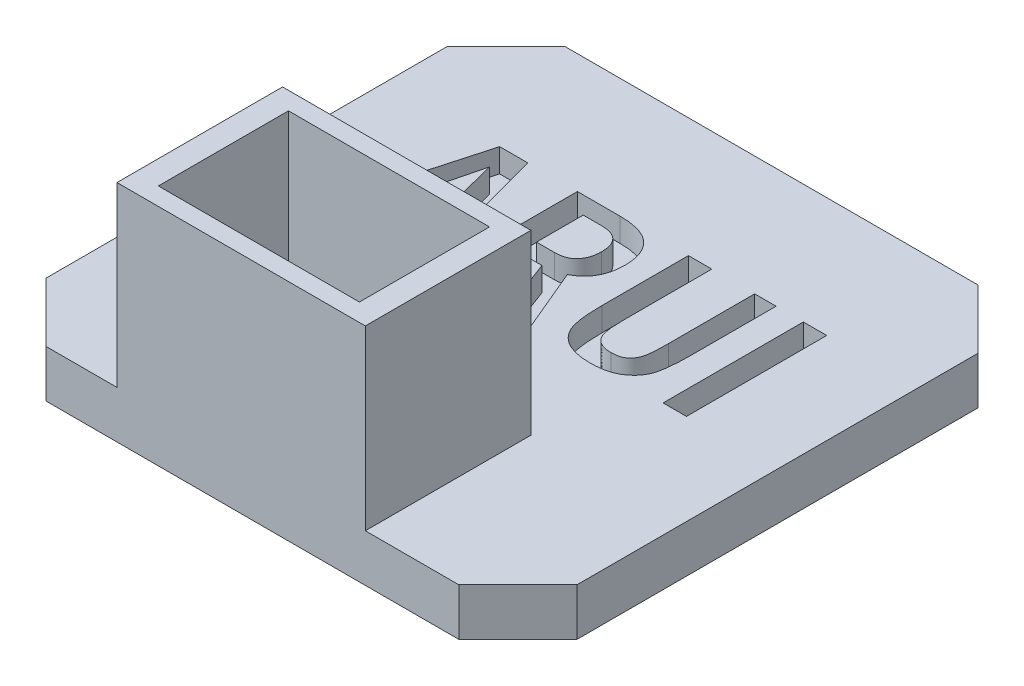
from build123d import *

# Parameters (mm, degrees)
SKETCH_1_W               = 44.9
SKETCH_1_H               = 43.9
SKETCH_1_W_2             = 15
SKETCH_1_H_2             = 8
EXTRUDE_1_DEPTH          = 4
SKETCH_2_W               = 21
SKETCH_2_H               = 14
EXTRUDE_2_DEPTH          = 15
CHAMFER_1_SIZE           = 5
SKETCH_6_W               = 1.976106771
SKETCH_6_H               = 11.856640625
CUT_EXTRUDE_2_DEPTH      = 2
SKETCH_8_W               = 17
SKETCH_8_H               = 11
CUT_EXTRUDE_3_DEPTH      = 16
CUT_EXTRUDE_3_DEPTH_BACK = 5


with BuildPart() as part:
    # 草圖1 → 填料-伸長1 (new body)
    with BuildSketch(Plane(origin=(0, 0, 0), x_dir=(1, 0, 0), z_dir=(0, 1, 0))):
        Rectangle(SKETCH_1_W, SKETCH_1_H)
        with Locations((-0.95, -14.95)):
            Rectangle(SKETCH_1_W_2, SKETCH_1_H_2, mode=Mode.SUBTRACT)
    extrude(amount=EXTRUDE_1_DEPTH)

    # 草圖2 → 填料-伸長2 (add)
    with BuildSketch(Plane(origin=(0, 4, 0), x_dir=(1, 0, 0), z_dir=(0, 1, 0))):
        with Locations((-0.95, -14.95)):
            Rectangle(SKETCH_2_W, SKETCH_2_H)
    extrude(amount=EXTRUDE_2_DEPTH)

    # 導角1
    chamfer_1_edges = [part.edges().sort_by_distance(p)[0] for p in [
        (22.45, 2, 21.95),
        (-22.45, 2, 21.95),
        (-22.45, 2, -21.95),
        (22.45, 2, -21.95),
    ]]
    chamfer(chamfer_1_edges, length=CHAMFER_1_SIZE)

    # 草圖6 → 除料-伸長2 (cut)
    with BuildSketch(Plane(origin=(0, 4, 0), x_dir=(1, 0, 0), z_dir=(0, 1, 0))):
        with Locations((13.763161733, 5.928320313)):
            Rectangle(SKETCH_6_W, SKETCH_6_H)
        with BuildLine():
            Line((3.059250057, 11.856640625), (5.035356828, 11.856640625))
            Line((5.035356828, 11.856640625), (5.035356828, 4.551735518))
            add(Edge.make_bspline(
                [(5.035356828, 4.551735518), (5.036076363, 4.453101504), (5.03746547, 4.262682412), (5.041721712, 3.986432719), (5.052471557, 3.730843331), (5.065419378, 3.494966916), (5.079852308, 3.27948879), (5.100219748, 3.082906695), (5.126020768, 2.907092971), (5.161907363, 2.702518739), (5.227181859, 2.471396441), (5.346042075, 2.220817069), (5.505658083, 2.000940309), (5.703716477, 1.813287236), (5.940999948, 1.661095057), (6.219106546, 1.557611062), (6.532345348, 1.491403159), (6.753787388, 1.485287872), (6.869945535, 1.482080078)],
                knots=[0, 0, 0, 0, 0.000295913, 0.000571278, 0.000828789, 0.00106329, 0.001279978, 0.00147661, 0.001656006, 0.001812962, 0.002099601, 0.002373508, 0.002640623, 0.002909996, 0.003187659, 0.003480095, 0.003795491, 0.004143463, 0.004143463, 0.004143463, 0.004143463], degree=3))
            add(Edge.make_bspline(
                [(6.869945535, 1.482080078), (6.979108166, 1.485323674), (7.185914857, 1.491468608), (7.478103452, 1.542772134), (7.734040216, 1.627547385), (7.95021072, 1.755507522), (8.133767296, 1.912470394), (8.286413423, 2.09937152), (8.408543434, 2.31572029), (8.488752812, 2.518695759), (8.538719302, 2.708124745), (8.572249599, 2.884248328), (8.595337293, 3.09258123), (8.619330721, 3.330911167), (8.636733743, 3.600388759), (8.649285633, 3.901507913), (8.656877974, 4.234353462), (8.65776025, 4.466820697), (8.658219241, 4.587758297)],
                knots=[0, 0, 0, 0, 0.000327274, 0.000620015, 0.000886919, 0.0011314, 0.001368624, 0.001608139, 0.001851331, 0.00211126, 0.002260431, 0.002438567, 0.002648567, 0.002888979, 0.003157183, 0.003458505, 0.003793091, 0.004155901, 0.004155901, 0.004155901, 0.004155901], degree=3))
            Line((8.658219241, 4.587758297), (8.658219241, 11.856640625))
            Line((8.658219241, 11.856640625), (10.469650447, 11.856640625))
            Line((10.469650447, 11.856640625), (10.469650447, 4.662376912))
            add(Edge.make_bspline(
                [(10.469650447, 4.662376912), (10.469685194, 4.522559264), (10.469752785, 4.25057684), (10.455113748, 3.855177984), (10.438192626, 3.484519322), (10.413661802, 3.138502656), (10.376356615, 2.817901568), (10.336730834, 2.521504109), (10.287549939, 2.250256089), (10.231684945, 2.000580883), (10.162505873, 1.767205545), (10.071732473, 1.547542781), (9.960736289, 1.338048469), (9.828661623, 1.139809468), (9.677928336, 0.950611132), (9.509049938, 0.769826189), (9.315912759, 0.603686172), (9.1088874, 0.442574938), (8.880127688, 0.298580443), (8.631190093, 0.175649961), (8.365081478, 0.068421916), (8.078074224, -0.013645552), (7.774795746, -0.085791287), (7.451596287, -0.129284291), (7.110649151, -0.158790725), (6.876876836, -0.162677818), (6.756731085, -0.164675564)],
                knots=[0, 0, 0, 0, 0.000419416, 0.000815875, 0.001186833, 0.001532581, 0.001856224, 0.002154976, 0.002429534, 0.002682951, 0.002922259, 0.003158784, 0.003394749, 0.003632391, 0.003872293, 0.004119842, 0.004373272, 0.004635736, 0.004906299, 0.005182468, 0.005467717, 0.005765681, 0.006077149, 0.006402098, 0.006742919, 0.007103294, 0.007103294, 0.007103294, 0.007103294], degree=3))
            add(Edge.make_bspline(
                [(6.756731085, -0.164675564), (6.572088823, -0.160672713), (6.213313186, -0.152894832), (5.693888541, -0.080141082), (5.212443662, 0.040519199), (4.839217856, 0.180134285), (4.562586357, 0.318206014), (4.372061993, 0.439268416), (4.190774021, 0.571595268), (4.024911338, 0.720227999), (3.870905603, 0.884748387), (3.730939107, 1.063229374), (3.603348846, 1.25712115), (3.484339549, 1.467460569), (3.383176765, 1.710084607), (3.296442596, 1.990166437), (3.223495537, 2.312081765), (3.161765625, 2.675333521), (3.117259984, 3.080076219), (3.084216843, 3.526351598), (3.063829241, 4.01463861), (3.060816635, 4.354447779), (3.059250057, 4.531151072)],
                knots=[0, 0, 0, 0, 0.000553691, 0.00107587, 0.001569501, 0.002040208, 0.002268051, 0.002495792, 0.002716565, 0.002940717, 0.003162806, 0.003391866, 0.003620231, 0.003858652, 0.004115764, 0.0044071, 0.004737274, 0.005105293, 0.005511909, 0.005958303, 0.006447616, 0.006977722, 0.006977722, 0.006977722, 0.006977722], degree=3))
            Line((3.059250057, 4.531151072), (3.059250057, 11.856640625))
        make_face()
        with BuildLine():
            Line((-6.327257105, 11.856640625), (-2.727552193, 11.856640625))
            add(Edge.make_bspline(
                [(-2.727552193, 11.856640625), (-2.569654474, 11.854501299), (-2.264428289, 11.850365847), (-1.82306127, 11.809422514), (-1.414120553, 11.738897543), (-1.03504224, 11.648002947), (-0.6908152, 11.517865904), (-0.373541071, 11.37206399), (-0.091926106, 11.190128252), (0.157855246, 10.98196376), (0.377514959, 10.749773263), (0.567450669, 10.492140853), (0.725912096, 10.210547384), (0.860114733, 9.906330602), (0.95784615, 9.576430181), (1.030283457, 9.223550245), (1.074257755, 8.847267053), (1.080128778, 8.588120925), (1.083143286, 8.455061001)],
                knots=[0, 0, 0, 0, 0.000473617, 0.000915531, 0.001327967, 0.001718004, 0.002082707, 0.002430288, 0.002763606, 0.003085145, 0.003403675, 0.003720171, 0.00404283, 0.004371235, 0.004715535, 0.00507281, 0.005451014, 0.005850136, 0.005850136, 0.005850136, 0.005850136], degree=3))
            add(Edge.make_bspline(
                [(1.083143286, 8.455061001), (1.077874288, 8.278897277), (1.067660165, 7.937398216), (0.98435292, 7.445373037), (0.848181333, 6.992498268), (0.657388108, 6.578527022), (0.407656268, 6.205410431), (0.098975839, 5.877643903), (-0.259123171, 5.583123287), (-0.531825254, 5.42861993), (-0.671680695, 5.349382782)],
                knots=[0, 0, 0, 0, 0.000528235, 0.001024001, 0.001492021, 0.001943276, 0.002386447, 0.002832506, 0.003289816, 0.003771252, 0.003771252, 0.003771252, 0.003771252], degree=3))
            Line((-0.671680695, 5.349382782), (1.577169979, 0))
            Line((1.577169979, 0), (-0.566185412, 0))
            Line((-0.566185412, 0), (-2.408493287, 4.940266927))
            Line((-2.408493287, 4.940266927), (-4.351150334, 4.940266927))
            Line((-4.351150334, 4.940266927), (-4.351150334, 0))
            Line((-4.351150334, 0), (-6.327257105, 0))
            Line((-6.327257105, 0), (-6.327257105, 11.856640625))
        make_face()
        with BuildLine():
            Line((-4.351150334, 10.374560547), (-4.351150334, 6.422347005))
            Line((-4.351150334, 6.422347005), (-2.84848581, 6.422347005))
            add(Edge.make_bspline(
                [(-2.84848581, 6.422347005), (-2.766891206, 6.42318571), (-2.609163984, 6.424806977), (-2.381414683, 6.455471211), (-2.169798722, 6.497108704), (-1.974894326, 6.559618036), (-1.796318315, 6.638643077), (-1.635093402, 6.737925118), (-1.489496191, 6.853531163), (-1.321825512, 7.034798612), (-1.14459384, 7.293601165), (-0.999561359, 7.650998331), (-0.905685397, 8.04799541), (-0.897318819, 8.327547685), (-0.892963485, 8.473072391)],
                knots=[0, 0, 0, 0, 0.000244562, 0.000472753, 0.00068823, 0.000890849, 0.001085485, 0.001272594, 0.001457443, 0.001641286, 0.002011681, 0.002391108, 0.002792447, 0.003228214, 0.003228214, 0.003228214, 0.003228214], degree=3))
            add(Edge.make_bspline(
                [(-0.892963485, 8.473072391), (-0.894279915, 8.549484378), (-0.896845222, 8.698387142), (-0.921435121, 8.913994847), (-0.95504089, 9.116257437), (-1.010421463, 9.302883616), (-1.078825106, 9.474653372), (-1.162439303, 9.631740361), (-1.259889976, 9.774243344), (-1.375072383, 9.901052819), (-1.502951485, 10.015647003), (-1.650085041, 10.110460751), (-1.809818319, 10.193746383), (-1.985420652, 10.259709745), (-2.175655038, 10.312163257), (-2.380987364, 10.346000099), (-2.600878696, 10.370767484), (-2.752348144, 10.373269853), (-2.83047442, 10.374560547)],
                knots=[0, 0, 0, 0, 0.000229132, 0.000446506, 0.000650411, 0.00084339, 0.001029257, 0.001204225, 0.001376235, 0.001545686, 0.00171706, 0.001889762, 0.002069286, 0.002256608, 0.002451363, 0.002660335, 0.002880268, 0.003114543, 0.003114543, 0.003114543, 0.003114543], degree=3))
            Line((-2.83047442, 10.374560547), (-4.351150334, 10.374560547))
        make_face(mode=Mode.SUBTRACT)
        Polygon((-12.901414396, 11.856640625), (-10.513618714, 11.856640625), (-7.31531049, 0), (-9.304282539, 0), (-10.060760913, 2.964160156), (-13.590993321, 2.964160156), (-14.334606416, 0), (-16.207790959, 0), align=None)
        Polygon((-10.441573155, 4.446240234), (-11.843888507, 9.944860246), (-13.220473301, 4.446240234), align=None, mode=Mode.SUBTRACT)
    extrude(amount=-CUT_EXTRUDE_2_DEPTH, mode=Mode.SUBTRACT)

    # 草圖8 → 除料-伸長3 (cut, two sides)
    with BuildSketch(Plane(origin=(0, 4, 0), x_dir=(1, 0, 0), z_dir=(0, 1, 0))) as cut_extrude_3_sk:
        with Locations((-0.95, -14.95)):
            Rectangle(SKETCH_8_W, SKETCH_8_H)
    extrude(amount=CUT_EXTRUDE_3_DEPTH, mode=Mode.SUBTRACT)
    extrude(cut_extrude_3_sk.sketch, amount=-CUT_EXTRUDE_3_DEPTH_BACK, mode=Mode.SUBTRACT)


solid = part.part
